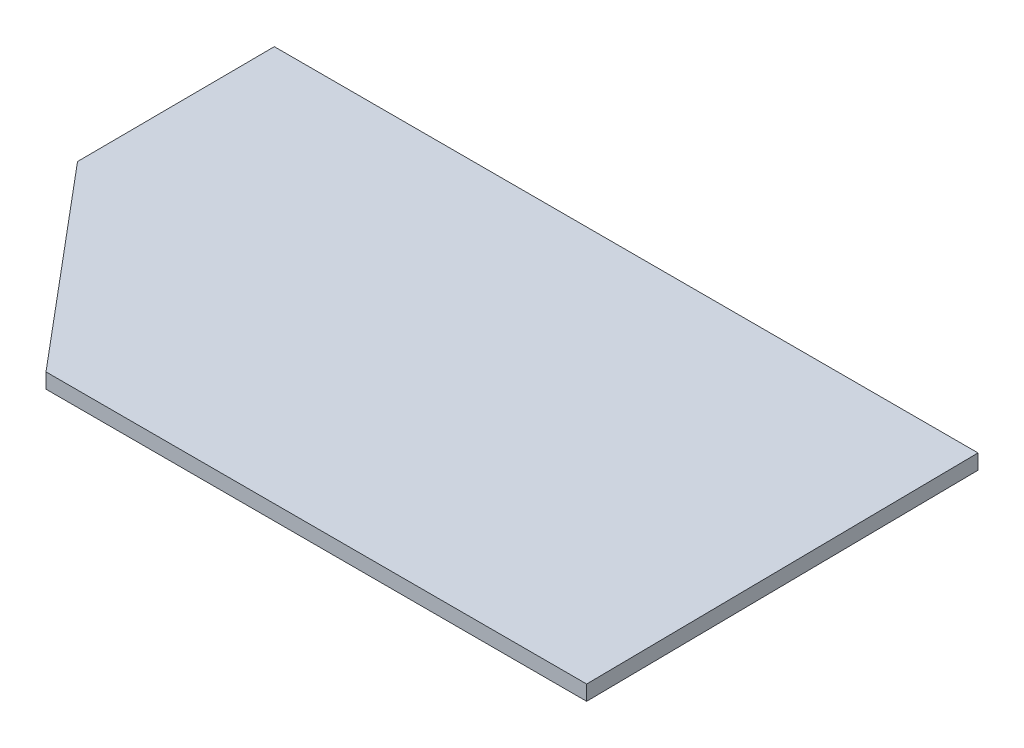
from build123d import *

# Parameters (mm, degrees)
BOSS_EXTRU_1_DEPTH = 2


with BuildPart() as part:
    # Esquisse1 → Boss.-Extru.1 (new body)
    with BuildSketch(Plane(origin=(0, 0, 0), x_dir=(1, 0, 0), z_dir=(0, 1, 0))):
        Polygon((-22.1630686, 26.361751479), (0, 0), (72.017974668, 0), (71.421629321, 52.723502957), (-22.308162531, 52.723502957), align=None)
    extrude(amount=BOSS_EXTRU_1_DEPTH)


solid = part.part
